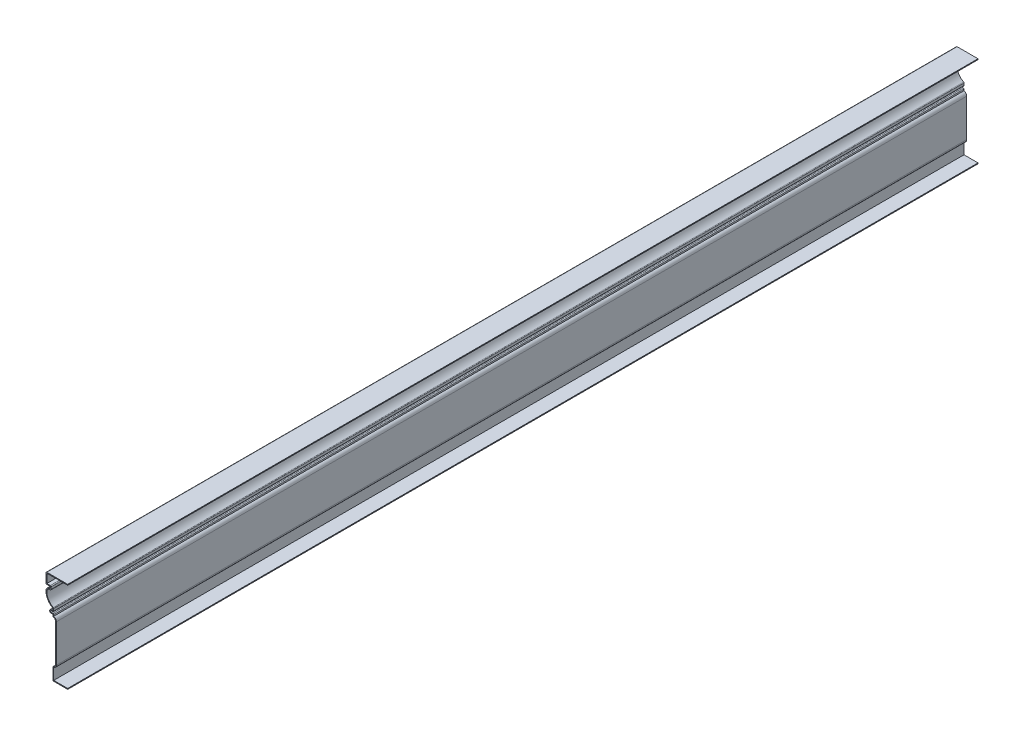
from build123d import *

# Parameters (mm, degrees)
EXTRUDE_THIN1_DEPTH = 1365.25
FILLET1_R           = 1.27


with BuildPart() as part:
    # Sketch1 → Extrude-Thin1 (new body)
    with BuildSketch(Plane.XY):
        with BuildLine():
            Line((0, 0), (-22.225, 0))
            Line((-22.225, 0), (-22.225, 19.05))
            ThreePointArc((-22.225, 19.05), (-19.418669962, 20.212419962), (-18.25625, 23.01875))
            Line((-18.25625, 23.01875), (-18.25625, 79.375))
            ThreePointArc((-18.25625, 79.375), (-19.418669962, 82.181330038), (-22.225, 83.34375))
            Line((-22.225, 83.34375), (-22.225, 86.51875))
            Line((-22.225, 86.51875), (-24.765, 86.51875))
            ThreePointArc((-24.765, 86.51875), (-27.14625, 88.9), (-24.765, 91.28125))
            Line((-24.765, 91.28125), (-22.225, 91.28125))
            Line((-22.225, 91.28125), (-22.225, 94.45625))
            ThreePointArc((-22.225, 94.45625), (-30.157584675, 102.15609622), (-32.478342254, 112.964778641))
            ThreePointArc((-32.478342254, 112.964778641), (-30.377697482, 116.671337824), (-26.19375, 117.475))
            Line((-26.19375, 117.475), (-26.19375, 120.65))
            Line((-26.19375, 120.65), (-32.54375, 120.65))
            Line((-32.54375, 120.65), (-32.54375, 136.525))
            Line((-32.54375, 136.525), (0, 136.525))
            Line((0, 136.525), (0, 135.255))
            Line((0, 135.255), (-31.27375, 135.255))
            Line((-31.27375, 135.255), (-31.27375, 121.92))
            Line((-31.27375, 121.92), (-24.92375, 121.92))
            Line((-24.92375, 121.92), (-24.92375, 115.426165066))
            ThreePointArc((-24.92375, 115.426165066), (-28.855388092, 116.071729842), (-31.21270277, 112.859627808))
            ThreePointArc((-31.21270277, 112.859627808), (-28.857537425, 102.438637116), (-20.955, 95.248800326))
            Line((-20.955, 95.248800326), (-20.955, 90.01125))
            Line((-20.955, 90.01125), (-24.765, 90.01125))
            ThreePointArc((-24.765, 90.01125), (-25.87625, 88.9), (-24.765, 87.78875))
            Line((-24.765, 87.78875), (-20.955, 87.78875))
            Line((-20.955, 87.78875), (-20.955, 84.457479863))
            ThreePointArc((-20.955, 84.457479863), (-18.09597384, 82.599227742), (-16.98625, 79.375))
            Line((-16.98625, 79.375), (-16.98625, 23.01875))
            ThreePointArc((-16.98625, 23.01875), (-18.09597384, 19.794522258), (-20.955, 17.936270137))
            Line((-20.955, 17.936270137), (-20.955, 1.27))
            Line((-20.955, 1.27), (0, 1.27))
            Line((0, 1.27), (0, 0))
        make_face()
    extrude(amount=-EXTRUDE_THIN1_DEPTH)

    # Fillet1
    fillet1_edges = [part.edges().sort_by_distance(p)[0] for p in [
        (-24.92375, 121.92, -682.625),
        (-24.92375, 115.426165066, -682.625),
        (-20.955, 95.248800326, -682.625),
        (-20.955, 90.01125, -682.625),
        (-20.955, 87.78875, -682.625),
        (-22.225, 0, -682.625),
        (-22.225, 19.05, -682.625),
        (-22.225, 83.34375, -682.625),
        (-32.54375, 120.65, -682.625),
        (-32.54375, 136.525, -682.625),
    ]]
    fillet(fillet1_edges, radius=FILLET1_R)


solid = part.part
